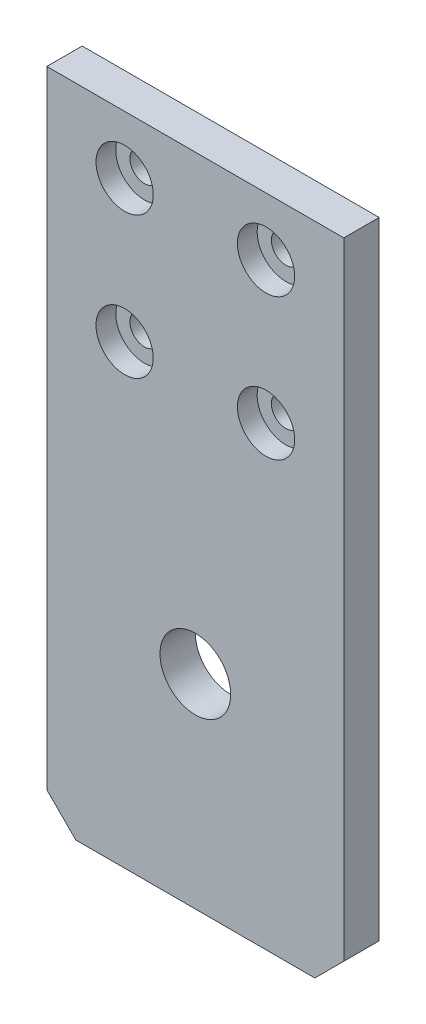
from build123d import *

# Parameters (mm, degrees)
CROQUIS1_W              = 42
CROQUIS1_H              = 85
CROQUIS1_R              = 2.05
SALIENTE_EXTRUIR1_DEPTH = 5
CROQUIS4_R              = 4.05
CORTAR_EXTRUIR1_DEPTH   = 2.8
CROQUIS7_R              = 5
CORTAR_EXTRUIR4_DEPTH   = 6
CROQUIS8_W              = 42
CROQUIS8_H              = 7.7
SALIENTE_EXTRUIR2_DEPTH = 5
CHAFL_N1_SIZE           = 4.1


with BuildPart() as part:
    # Croquis1 → Saliente-Extruir1 (new body)
    with BuildSketch(Plane.XY):
        with Locations((21, 42.5)):
            Rectangle(CROQUIS1_W, CROQUIS1_H)
        with Locations((11, 76.8)):
            Circle(CROQUIS1_R, mode=Mode.SUBTRACT)
        with Locations((31, 76.8)):
            Circle(CROQUIS1_R, mode=Mode.SUBTRACT)
        with Locations((31, 56.8)):
            Circle(CROQUIS1_R, mode=Mode.SUBTRACT)
        with Locations((11, 56.8)):
            Circle(CROQUIS1_R, mode=Mode.SUBTRACT)
    extrude(amount=SALIENTE_EXTRUIR1_DEPTH)

    # Croquis4 → Cortar-Extruir1 (cut)
    with BuildSketch(Plane.XY.offset(5)):
        with Locations((11, 76.8)):
            Circle(CROQUIS4_R)
        with Locations((11, 56.8)):
            Circle(CROQUIS4_R)
        with Locations((31, 56.8)):
            Circle(CROQUIS4_R)
        with Locations((31, 76.8)):
            Circle(CROQUIS4_R)
    extrude(amount=-CORTAR_EXTRUIR1_DEPTH, mode=Mode.SUBTRACT)

    # Croquis7 → Cortar-Extruir4 (cut, through all)
    with BuildSketch(Plane.XY.offset(5)):
        with Locations((21, 21.08)):
            Circle(CROQUIS7_R)
    extrude(amount=-CORTAR_EXTRUIR4_DEPTH, mode=Mode.SUBTRACT)

    # Croquis8 → Saliente-Extruir2 (add, through all)
    with BuildSketch(Plane.XY.offset(5)):
        with Locations((21, -3.85)):
            Rectangle(CROQUIS8_W, CROQUIS8_H)
    extrude(amount=-SALIENTE_EXTRUIR2_DEPTH)

    # Chaflán1
    chafl_n1_edges = [part.edges().sort_by_distance(p)[0] for p in [
        (0, -7.7, 2.5),
        (42, -7.7, 2.5),
    ]]
    chamfer(chafl_n1_edges, length=CHAFL_N1_SIZE)


solid = part.part
